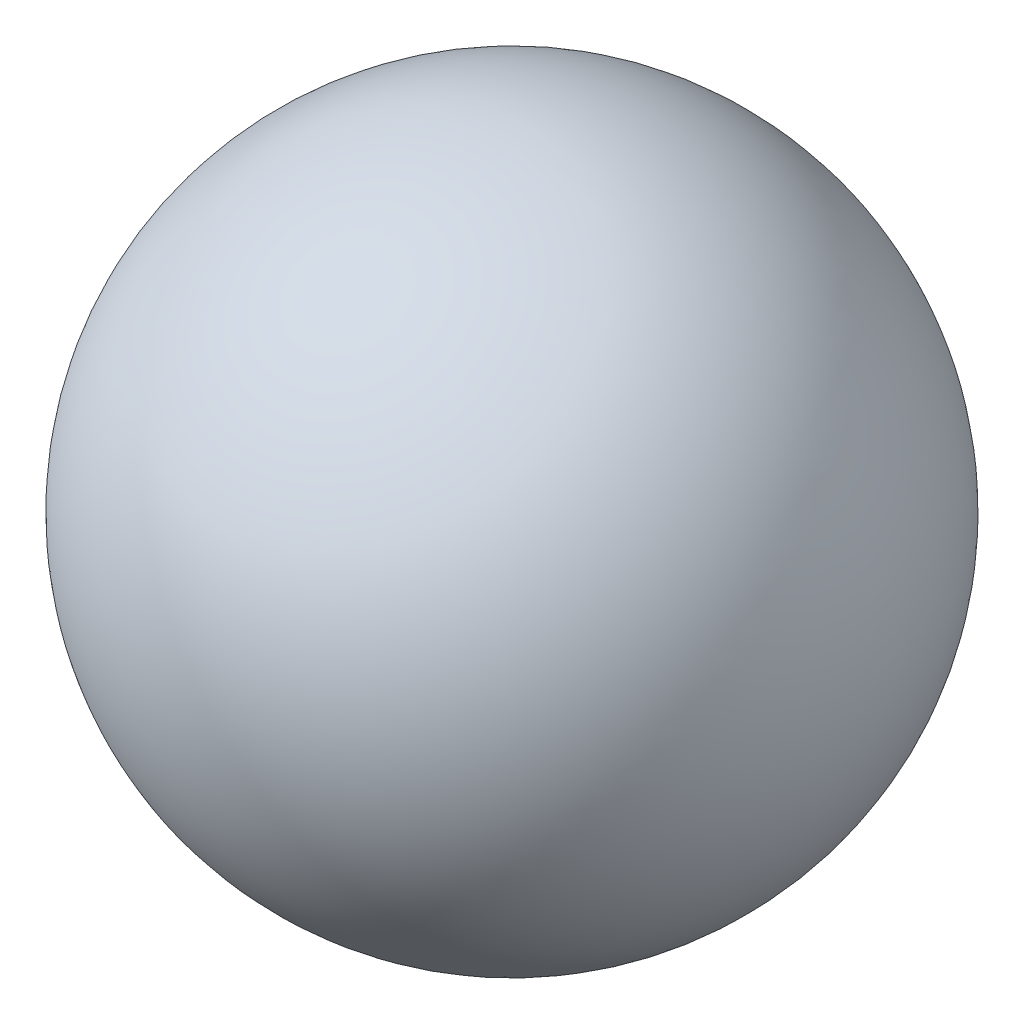
from build123d import *


with BuildPart() as part:
    # Sketch2 → Revolve3 (revolve)
    with BuildSketch(Plane(origin=(0, 0, 0), x_dir=(1, 0, 0), z_dir=(0, 1, 0))):
        with BuildLine():
            Line((0, 1.5), (0, -1.5))
            ThreePointArc((0, -1.5), (-1.5, 0), (0, 1.5))
        make_face()
    revolve(axis=Axis((0, 0, -1.5), (0, 0, 1)))


solid = part.part
